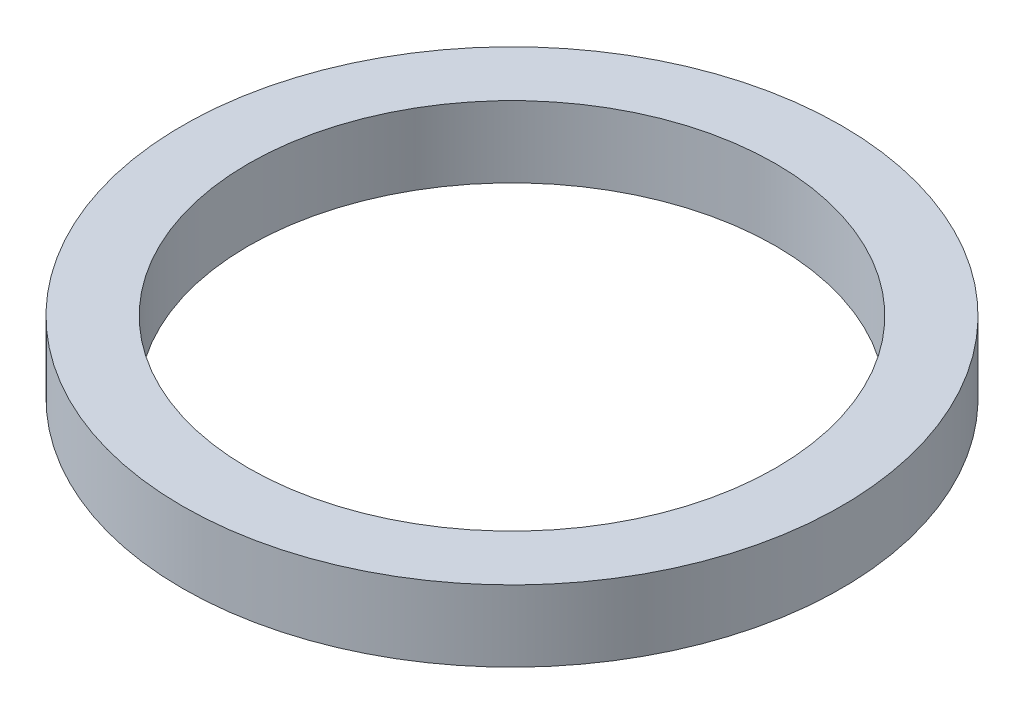
from build123d import *

# Parameters (mm, degrees)
SKIZZE1_R                       = 9.25
SKIZZE1_R_2                     = 7.4
AUFSATZ_LINEAR_AUSTRAGEN1_DEPTH = 2


with BuildPart() as part:
    # Skizze1 → Aufsatz-Linear austragen1 (new body)
    with BuildSketch(Plane(origin=(0, 0, 0), x_dir=(1, 0, 0), z_dir=(0, 1, 0))):
        Circle(SKIZZE1_R)
        Circle(SKIZZE1_R_2, mode=Mode.SUBTRACT)
    extrude(amount=AUFSATZ_LINEAR_AUSTRAGEN1_DEPTH)


solid = part.part
